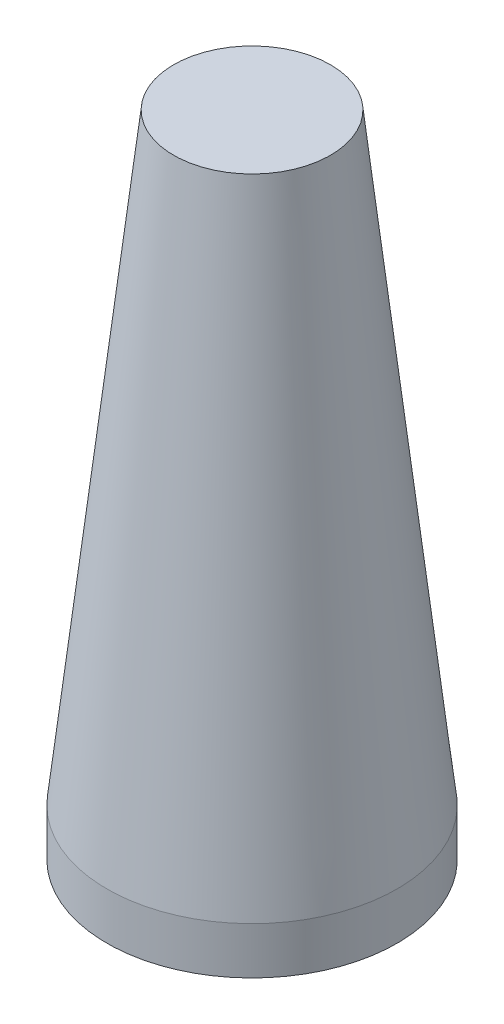
from build123d import *


with BuildPart() as part:
    # Sketch1 → Revolve1 (revolve)
    with BuildSketch(Plane.XY, mode=Mode.PRIVATE) as revolve1_sk:
        Polygon((-94.064695228, 790), (0, 790), (0, 800), (-100, 800), (-185, 32.501032947), (-185, -27.498967053), (-178, -27.498967053), (-178, 32.501032947), (-171.350171875, 92.501032947), (-20, 92.501032947), (-20, 570), (-118.429548867, 570), align=None)
        Polygon((-119.537042214, 560), (-27, 560), (-27, 102.501032947), (-170.241867187, 102.501032947), align=None, mode=Mode.SUBTRACT)
    revolve(revolve1_sk.sketch.rotate(Axis((0, -27.498967053, 0), (0, 1, 0)), 270), axis=Axis((0, -27.498967053, 0), (0, 1, 0)))


solid = part.part
